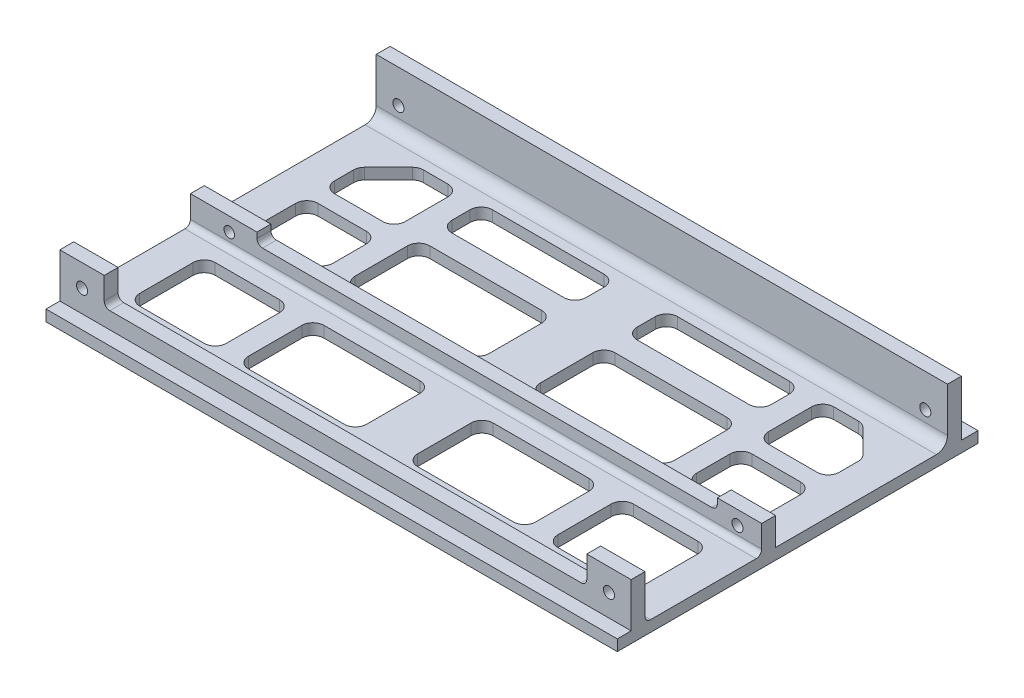
from build123d import *

# Parameters (mm, degrees)
SKETCH1_W            = 103
SKETCH1_H            = 62.04
BOSS_EXTRUDE1_DEPTH  = 2
SKETCH2_W            = 103
SKETCH2_H            = 2
BOSS_EXTRUDE2_DEPTH  = 3
SKETCH5_W            = 8
SKETCH5_H            = 2.5
BOSS_EXTRUDE4_DEPTH  = 10
BOSS_EXTRUDE5_DEPTH  = 10
SKETCH7_R            = 1
CUT_EXTRUDE1_DEPTH   = 3
FILLET2_R            = 2
SKETCH8_W            = 103
SKETCH8_H            = 2.5
BOSS_EXTRUDE6_DEPTH  = 3
SKETCH9_W            = 8
SKETCH9_H            = 2.5
BOSS_EXTRUDE7_DEPTH  = 2
SKETCH11_R           = 1
CUT_EXTRUDE3_DEPTH   = 22
FILLET4_R            = 1
SKETCH12_W           = 12
SKETCH12_H           = 2.5
BOSS_EXTRUDE8_DEPTH  = 2
FILLET5_R            = 1
SKETCH13_R           = 0.95132711
CUT_EXTRUDE4_DEPTH   = 12
FILLET6_R            = 1
SKETCH14_W           = 103
SKETCH14_H           = 2.5
BOSS_EXTRUDE9_DEPTH  = 3
SKETCH15_W           = 8
SKETCH15_H           = 2.5
BOSS_EXTRUDE10_DEPTH = 5
SKETCH16_R           = 1
CUT_EXTRUDE5_DEPTH   = 15
FILLET7_R            = 1
CUT_EXTRUDE6_DEPTH   = 5


with BuildPart() as part:
    # Sketch1 → Boss-Extrude1 (new body)
    with BuildSketch(Plane(origin=(0, 0, 0), x_dir=(1, 0, 0), z_dir=(0, 1, 0))):
        Rectangle(SKETCH1_W, SKETCH1_H)
    extrude(amount=BOSS_EXTRUDE1_DEPTH)

    # Sketch2 → Boss-Extrude2 (add)
    with BuildSketch(Plane(origin=(0, 0, -31.02), x_dir=(-1, 0, 0), z_dir=(0, 0, -1))):
        with Locations((0, 1)):
            Rectangle(SKETCH2_W, SKETCH2_H)
    extrude(amount=BOSS_EXTRUDE2_DEPTH)

    # Sketch5 → Boss-Extrude4 (add)
    with BuildSketch(Plane(origin=(0, 2, 0), x_dir=(1, 0, 0), z_dir=(0, 1, 0))):
        with Locations((47.5, 29.77)):
            Rectangle(SKETCH5_W, SKETCH5_H)
    boss_extrude4 = extrude(amount=BOSS_EXTRUDE4_DEPTH)

    # Sketch6 → Boss-Extrude5 (add)
    with BuildSketch(Plane(origin=(0, 2, 0), x_dir=(1, 0, 0), z_dir=(0, 1, 0))):
        Polygon((43.5, 28.52), (0, 28.52), (0, 30.925842428), (43.5, 31.02), align=None)
    boss_extrude5 = extrude(amount=BOSS_EXTRUDE5_DEPTH)

    # Sketch7 → Cut-Extrude1 (cut)
    with BuildSketch(Plane.XY.offset(-28.52)):
        with Locations((47.5, 6)):
            Circle(SKETCH7_R)
    cut_extrude1 = extrude(amount=-CUT_EXTRUDE1_DEPTH, mode=Mode.SUBTRACT)

    # Mirror1: Boss-Extrude4, Boss-Extrude5, Cut-Extrude1 across plane
    add(boss_extrude4.mirror(Plane(origin=(0, 0, 0), x_dir=(0, 0, 1), z_dir=(1, 0, 0))))
    add(boss_extrude5.mirror(Plane(origin=(0, 0, 0), x_dir=(0, 0, 1), z_dir=(1, 0, 0))))
    add(cut_extrude1.mirror(Plane(origin=(0, 0, 0), x_dir=(0, 0, 1), z_dir=(1, 0, 0))), mode=Mode.SUBTRACT)

    # Fillet2
    fillet2_edges = [part.edges().sort_by_distance(p)[0] for p in [
        (0, 2, -28.52),
    ]]
    fillet(fillet2_edges, radius=FILLET2_R)

    # Sketch8 → Boss-Extrude6 (add)
    with BuildSketch(Plane(origin=(0, 2, 0), x_dir=(1, 0, 0), z_dir=(0, 1, 0))):
        with Locations((0, -3.73)):
            Rectangle(SKETCH8_W, SKETCH8_H)
    extrude(amount=BOSS_EXTRUDE6_DEPTH)

    # Sketch9 → Boss-Extrude7 (add)
    with BuildSketch(Plane(origin=(0, 5, 0), x_dir=(1, 0, 0), z_dir=(0, 1, 0))):
        with Locations((47.5, -3.73)):
            Rectangle(SKETCH9_W, SKETCH9_H)
    extrude(amount=BOSS_EXTRUDE7_DEPTH)

    # Sketch11 → Cut-Extrude3 (cut)
    with BuildSketch(Plane.XY.offset(4.98)):
        with Locations((47.13, 4.5)):
            Circle(SKETCH11_R)
    extrude(amount=-CUT_EXTRUDE3_DEPTH, mode=Mode.SUBTRACT)

    # Fillet4
    fillet4_edges = [part.edges().sort_by_distance(p)[0] for p in [
        (0, 2, 4.98),
    ]]
    fillet(fillet4_edges, radius=FILLET4_R)

    # Sketch12 → Boss-Extrude8 (add)
    with BuildSketch(Plane(origin=(0, 5, 0), x_dir=(1, 0, 0), z_dir=(0, 1, 0))):
        with Locations((-45.5, -3.73)):
            Rectangle(SKETCH12_W, SKETCH12_H)
    extrude(amount=BOSS_EXTRUDE8_DEPTH)

    # Fillet5
    fillet5_edges = [part.edges().sort_by_distance(p)[0] for p in [
        (-39.5, 5, 3.73),
    ]]
    fillet(fillet5_edges, radius=FILLET5_R)

    # Sketch13 → Cut-Extrude4 (cut)
    with BuildSketch(Plane.XY.offset(4.98)):
        with Locations((-44.5, 4.5)):
            Circle(SKETCH13_R)
    extrude(amount=-CUT_EXTRUDE4_DEPTH, mode=Mode.SUBTRACT)

    # Fillet6
    fillet6_edges = [part.edges().sort_by_distance(p)[0] for p in [
        (43.5, 5, 3.73),
    ]]
    fillet(fillet6_edges, radius=FILLET6_R)

    # Sketch14 → Boss-Extrude9 (add)
    with BuildSketch(Plane(origin=(0, 2, 0), x_dir=(1, 0, 0), z_dir=(0, 1, 0))):
        with Locations((0, -27.27)):
            Rectangle(SKETCH14_W, SKETCH14_H)
    extrude(amount=BOSS_EXTRUDE9_DEPTH)

    # Sketch15 → Boss-Extrude10 (add)
    with BuildSketch(Plane(origin=(0, 5, 0), x_dir=(1, 0, 0), z_dir=(0, 1, 0))):
        with Locations((47.5, -27.27)):
            Rectangle(SKETCH15_W, SKETCH15_H)
        with Locations((-47.5, -27.27)):
            Rectangle(SKETCH15_W, SKETCH15_H)
    extrude(amount=BOSS_EXTRUDE10_DEPTH)

    # Sketch16 → Cut-Extrude5 (cut)
    with BuildSketch(Plane.XY.offset(31.02)):
        with Locations((47.5, 6)):
            Circle(SKETCH16_R)
        with Locations((-47.5, 6)):
            Circle(SKETCH16_R)
    extrude(amount=-CUT_EXTRUDE5_DEPTH, mode=Mode.SUBTRACT)

    # Fillet7
    fillet7_edges = [part.edges().sort_by_distance(p)[0] for p in [
        (0, 2, 26.02),
        (43.5, 5, 27.27),
        (-43.5, 5, 27.27),
    ]]
    fillet(fillet7_edges, radius=FILLET7_R)

    # Sketch17 → Cut-Extrude6 (cut)
    with BuildSketch(Plane(origin=(0, 2, 0), x_dir=(1, 0, 0), z_dir=(0, 1, 0))):
        with BuildLine():
            Line((43.5, -22.121075172), (31.88534696, -22.121075172))
            ThreePointArc((31.88534696, -22.121075172), (30.471133397, -21.535288735), (29.88534696, -20.121075172))
            Line((29.88534696, -20.121075172), (29.88534696, -10.50434013))
            ThreePointArc((29.88534696, -10.50434013), (30.471133397, -9.090126568), (31.88534696, -8.50434013))
            Line((31.88534696, -8.50434013), (43.5, -8.50434013))
            ThreePointArc((43.5, -8.50434013), (44.914213562, -9.090126568), (45.5, -10.50434013))
            Line((45.5, -10.50434013), (45.5, -20.121075172))
            ThreePointArc((45.5, -20.121075172), (44.914213562, -21.535288735), (43.5, -22.121075172))
        make_face()
        with BuildLine():
            Line((25.88534696, -20.121075172), (25.88534696, -10.50434013))
            ThreePointArc((25.88534696, -10.50434013), (25.299560522, -9.090126568), (23.88534696, -8.50434013))
            Line((23.88534696, -8.50434013), (6.608652469, -8.50434013))
            ThreePointArc((6.608652469, -8.50434013), (5.194438907, -9.090126568), (4.608652469, -10.50434013))
            Line((4.608652469, -10.50434013), (4.608652469, -20.121075172))
            ThreePointArc((4.608652469, -20.121075172), (5.194438907, -21.535288735), (6.608652469, -22.121075172))
            Line((6.608652469, -22.121075172), (23.88534696, -22.121075172))
            ThreePointArc((23.88534696, -22.121075172), (25.299560522, -21.535288735), (25.88534696, -20.121075172))
        make_face()
        with BuildLine():
            Line((44.914213562, 19.849036172), (40.619219164, 24.14403057))
            ThreePointArc((40.619219164, 24.14403057), (39.970372466, 24.577576073), (39.205005602, 24.729817008))
            Line((39.205005602, 24.729817008), (34.780809577, 24.729817008))
            ThreePointArc((34.780809577, 24.729817008), (33.366596015, 24.14403057), (32.780809577, 22.729817008))
            Line((32.780809577, 22.729817008), (32.780809577, 15.003047088))
            ThreePointArc((32.780809577, 15.003047088), (33.366596015, 13.588833526), (34.780809577, 13.003047088))
            Line((34.780809577, 13.003047088), (43.5, 13.003047088))
            ThreePointArc((43.5, 13.003047088), (44.914213562, 13.588833526), (45.5, 15.003047088))
            Line((45.5, 15.003047088), (45.5, 18.43482261))
            ThreePointArc((45.5, 18.43482261), (45.347759065, 19.200189474), (44.914213562, 19.849036172))
        make_face()
        with BuildLine():
            Line((43.5, 10.003047088), (34.780809577, 10.003047088))
            ThreePointArc((34.780809577, 10.003047088), (33.366596015, 9.417260651), (32.780809577, 8.003047088))
            Line((32.780809577, 8.003047088), (32.780809577, 2))
            ThreePointArc((32.780809577, 2), (33.366596015, 0.585786438), (34.780809577, 0))
            Line((34.780809577, 0), (43.5, 0))
            ThreePointArc((43.5, 0), (44.914213562, 0.585786438), (45.5, 2))
            Line((45.5, 2), (45.5, 8.003047088))
            ThreePointArc((45.5, 8.003047088), (44.914213562, 9.417260651), (43.5, 10.003047088))
        make_face()
        with BuildLine():
            Line((28.780809577, 2), (28.780809577, 11.452131966))
            ThreePointArc((28.780809577, 11.452131966), (28.19502314, 12.866345529), (26.780809577, 13.452131966))
            Line((26.780809577, 13.452131966), (6.608652469, 13.452131966))
            ThreePointArc((6.608652469, 13.452131966), (5.194438907, 12.866345529), (4.608652469, 11.452131966))
            Line((4.608652469, 11.452131966), (4.608652469, 2))
            ThreePointArc((4.608652469, 2), (5.194438907, 0.585786438), (6.608652469, 0))
            Line((6.608652469, 0), (26.780809577, 0))
            ThreePointArc((26.780809577, 0), (28.19502314, 0.585786438), (28.780809577, 2))
        make_face()
        with BuildLine():
            Line((28.780809577, 19.452131966), (28.780809577, 22.729817008))
            ThreePointArc((28.780809577, 22.729817008), (28.19502314, 24.14403057), (26.780809577, 24.729817008))
            Line((26.780809577, 24.729817008), (6.608652469, 24.729817008))
            ThreePointArc((6.608652469, 24.729817008), (5.194438907, 24.14403057), (4.608652469, 22.729817008))
            Line((4.608652469, 22.729817008), (4.608652469, 19.452131966))
            ThreePointArc((4.608652469, 19.452131966), (5.194438907, 18.037918404), (6.608652469, 17.452131966))
            Line((6.608652469, 17.452131966), (26.780809577, 17.452131966))
            ThreePointArc((26.780809577, 17.452131966), (28.19502314, 18.037918404), (28.780809577, 19.452131966))
        make_face()
    cut_extrude6 = extrude(amount=-CUT_EXTRUDE6_DEPTH, mode=Mode.SUBTRACT)

    # Mirror4: Cut-Extrude6 across plane
    add(cut_extrude6.mirror(Plane(origin=(0, 0, 0), x_dir=(0, 0, 1), z_dir=(1, 0, 0))), mode=Mode.SUBTRACT)


solid = part.part
